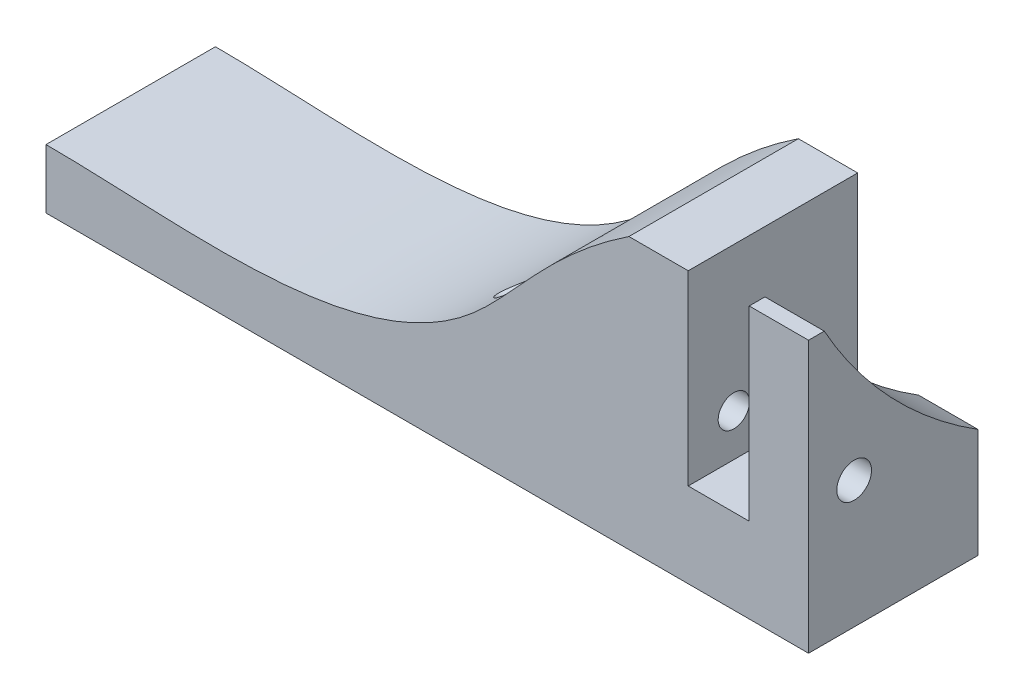
from build123d import *

# Parameters (mm, degrees)
BOSS_EXTRUDE1_DEPTH = 20
SKETCH2_R           = 53
SKETCH2_R_2         = 2.05
CUT_EXTRUDE1_DEPTH  = 14.2
SKETCH4_R           = 1.85
CUT_EXTRUDE2_DEPTH  = 56


with BuildPart() as part:
    # Sketch1 → Boss-Extrude1 (new body)
    with BuildSketch(Plane.XY):
        with BuildLine():
            Line((0, 130.395512055), (0, 108.395512055))
            Line((0, 108.395512055), (-7.2, 108.395512055))
            Line((-7.2, 108.395512055), (-7.2, 130.395512055))
            Line((-7.2, 130.395512055), (-14.2, 130.395512055))
            add(Edge.make_bspline(
                [(-14.2, 130.395512055), (-23.530576474, 124.205565192), (-38.446210931, 100.318296321), (-66.691471381, 105.395512055), (-83, 105.395512055)],
                knots=[0, 0, 0, 0, 0.267223526, 1, 1, 1, 1], degree=3))
            Line((-83, 105.395512055), (-83, 98.395512055))
            Line((-83, 98.395512055), (7, 98.395512055))
            Line((7, 98.395512055), (7, 130.395512055))
            Line((7, 130.395512055), (0, 130.395512055))
        make_face()
    extrude(amount=BOSS_EXTRUDE1_DEPTH)

    # Sketch2 → Cut-Extrude1 (cut)
    with BuildSketch(Plane(origin=(7, 0, 0), x_dir=(0, 0, -1), z_dir=(1, 0, 0))):
        with Locations((28.164207495, 156.175472317)):
            Circle(SKETCH2_R)
        with Locations((-14.615752767, 113.395512055)):
            Circle(SKETCH2_R_2)
    extrude(amount=-CUT_EXTRUDE1_DEPTH, mode=Mode.SUBTRACT)

    # Sketch4 → Cut-Extrude2 (cut)
    with BuildSketch(Plane(origin=(7, 0, 0), x_dir=(0, 0, -1), z_dir=(1, 0, 0))):
        with Locations((-14.615752767, 113.395512055)):
            Circle(SKETCH4_R)
    extrude(amount=-CUT_EXTRUDE2_DEPTH, mode=Mode.SUBTRACT)


solid = part.part
